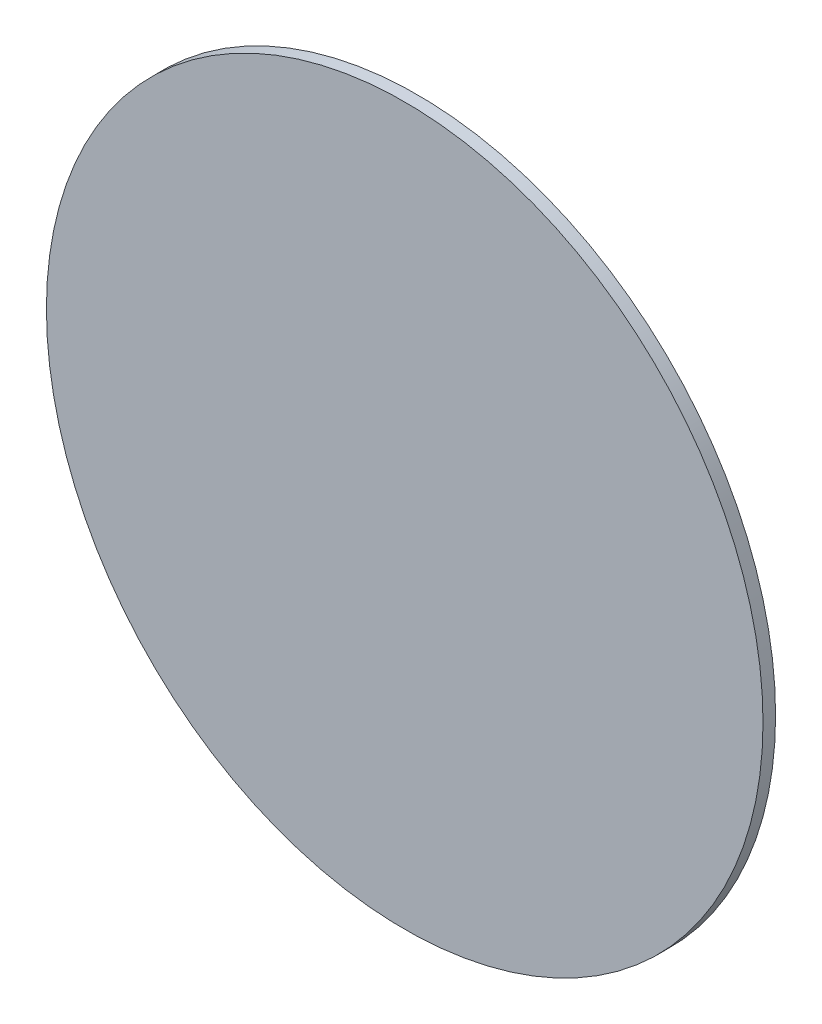
from build123d import *

# Parameters (mm, degrees)
ESBO_O1_R                = 28.5
RESSALTO_EXTRUS_O1_DEPTH = 1


with BuildPart() as part:
    # Esboço1 → Ressalto-extrusão1 (new body)
    with BuildSketch(Plane.XY):
        Circle(ESBO_O1_R)
    extrude(amount=RESSALTO_EXTRUS_O1_DEPTH)


solid = part.part
